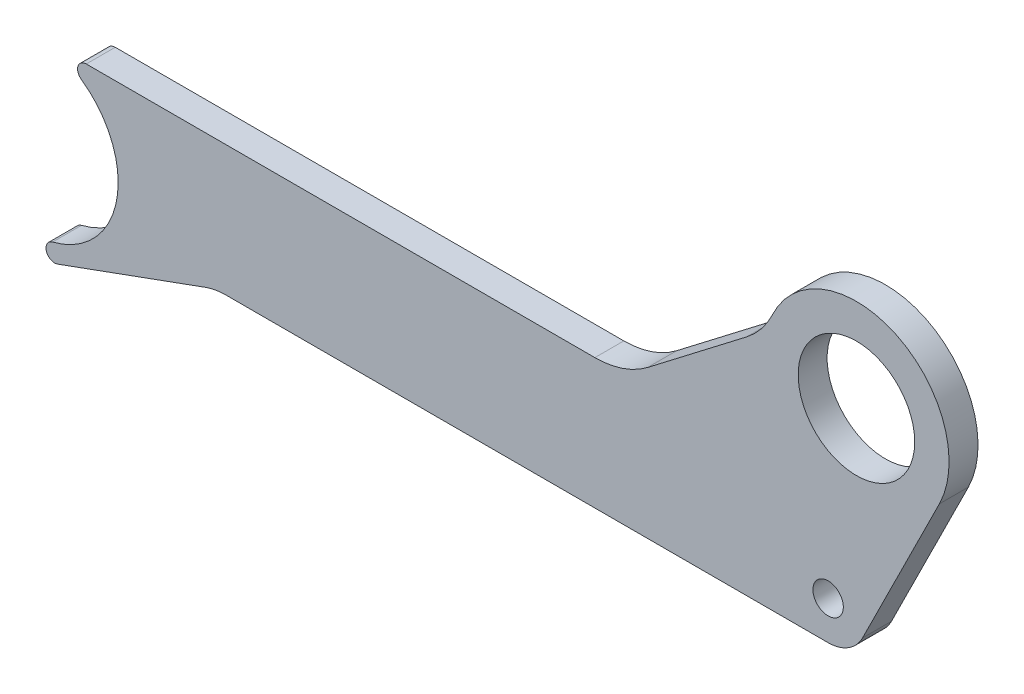
from build123d import *

# Parameters (mm, degrees)
SKETCH1_R      = 20.125
SKETCH1_R_2    = 5.25
EXTRUDE1_DEPTH = 10


with BuildPart() as part:
    # Sketch1 → Extrude1 (new body)
    with BuildSketch(Plane.XY):
        with BuildLine():
            Line((-37.923361282, 2.412191764), (-72.084536873, -23.800600209))
            ThreePointArc((-72.084536873, -23.800600209), (-80.704195785, -28.407903885), (-90.347379744, -30))
            Line((-90.347379744, -30), (-266.026334039, -30))
            ThreePointArc((-266.026334039, -30), (-268.886721807, -32.095465966), (-267.751212763, -35.454545455))
            ThreePointArc((-267.751212763, -35.454545455), (-255.500241033, -65.45565953), (-277.670674774, -89.090909091))
            ThreePointArc((-277.670674774, -89.090909091), (-279.805574248, -92.880647284), (-275.911681822, -94.819077862))
            Line((-275.911681822, -94.819077862), (-224.773076173, -76.206147584))
            ThreePointArc((-224.773076173, -76.206147584), (-221.40563686, -75.30384494), (-217.932673306, -75))
            Line((-217.932673306, -75), (-9.777154065, -75))
            ThreePointArc((-9.777154065, -75), (-2.78855267, -73.010526422), (2.10446711, -67.638663429))
            Line((2.10446711, -67.638663429), (28.653113345, -14.247775111))
            ThreePointArc((28.653113345, -14.247775111), (13.889557824, 28.828461344), (-28.999331175, 13.529182954))
            ThreePointArc((-28.999331175, 13.529182954), (-32.791417533, 7.432910208), (-37.923361282, 2.412191764))
        make_face()
        Circle(SKETCH1_R, mode=Mode.SUBTRACT)
        with Locations((-9.777154065, -61.730521287)):
            Circle(SKETCH1_R_2, mode=Mode.SUBTRACT)
    extrude(amount=EXTRUDE1_DEPTH)


solid = part.part
